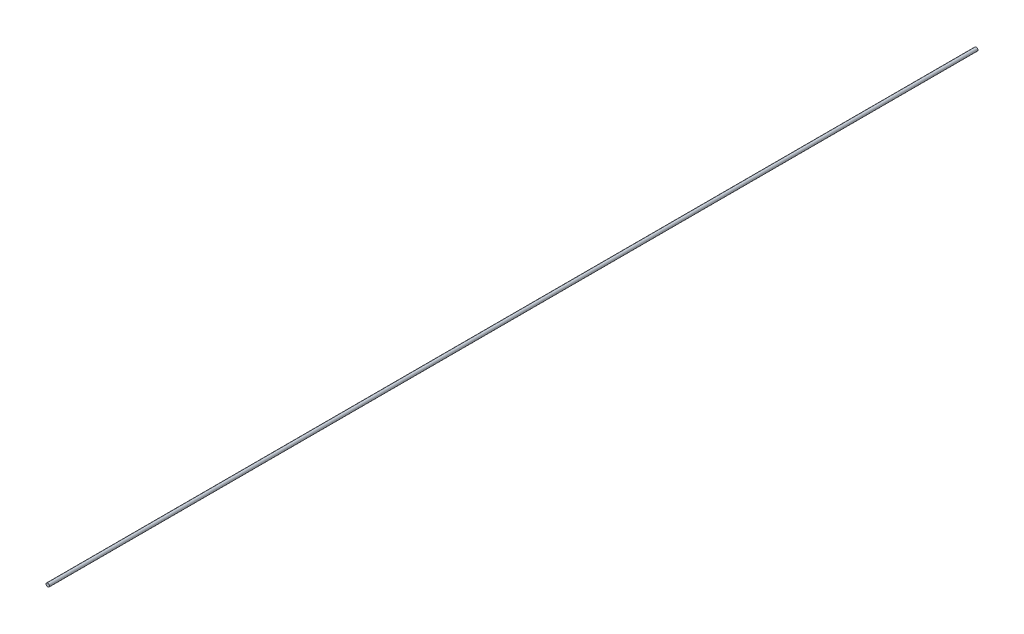
from build123d import *

# Parameters (mm, degrees)
SKETCH1_R           = 0.5
BOSS_EXTRUDE1_DEPTH = 270


with BuildPart() as part:
    # Sketch1 → Boss-Extrude1 (new body)
    with BuildSketch(Plane.XY):
        Circle(SKETCH1_R)
    extrude(amount=BOSS_EXTRUDE1_DEPTH)


solid = part.part
